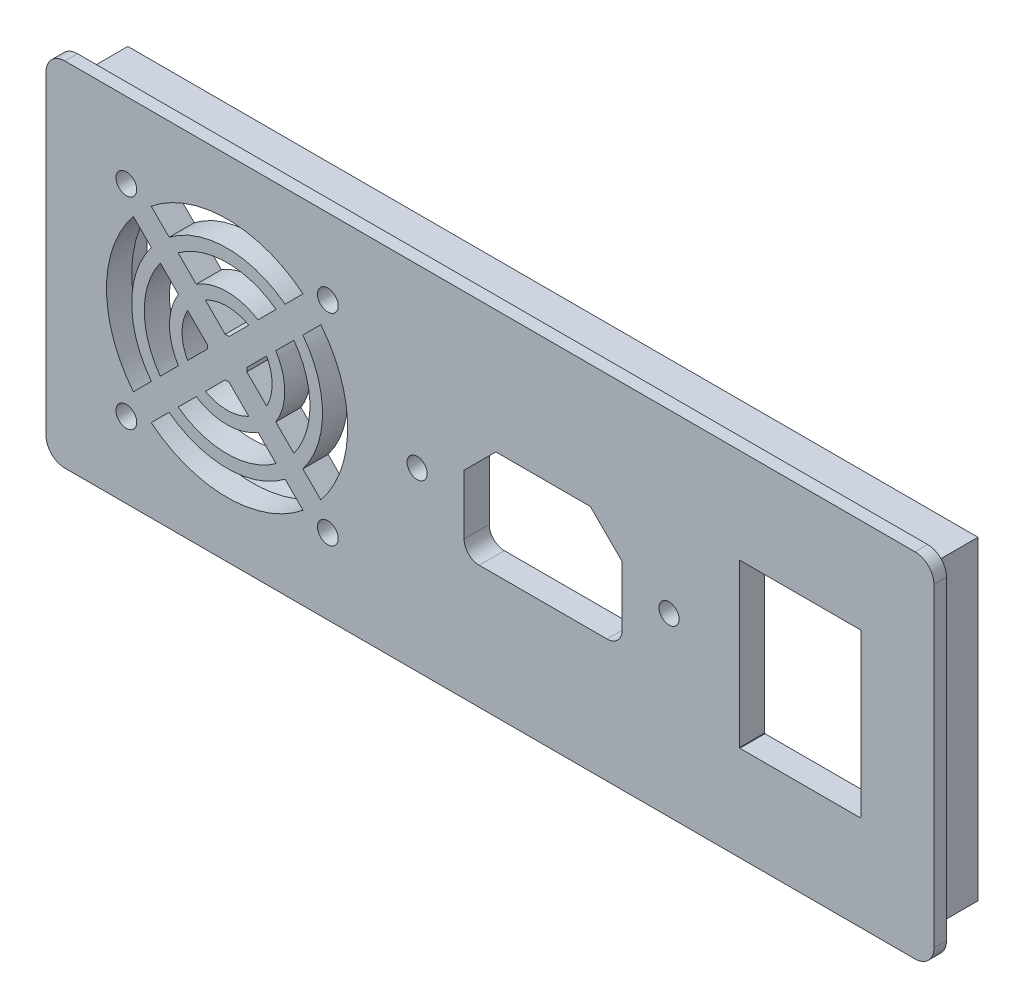
from build123d import *

# Parameters (mm, degrees)
CROQUIS1_W              = 135
CROQUIS1_H              = 50
CROQUIS1_R              = 1.65
CROQUIS1_R_2            = 1.6
SALIENTE_EXTRUIR1_DEPTH = 4
CROQUIS2_W              = 135
CROQUIS2_H              = 50
SALIENTE_EXTRUIR2_DEPTH = 2
CROQUIS3_W              = 135
CROQUIS3_H              = 50
CROQUIS3_R              = 0.85
SALIENTE_EXTRUIR3_DEPTH = 6


with BuildPart() as part:
    # Croquis1 → Saliente-Extruir1 (new body)
    with BuildSketch(Plane.XY):
        with Locations((0.24843477, -0.062108693)):
            Rectangle(CROQUIS1_W, CROQUIS1_H)
        with Locations((-57.493419725, 15.937891307)):
            Circle(CROQUIS1_R, mode=Mode.SUBTRACT)
        with Locations((-25.493419725, 15.937891307)):
            Circle(CROQUIS1_R, mode=Mode.SUBTRACT)
        with Locations((-25.493419725, -16.062108693)):
            Circle(CROQUIS1_R, mode=Mode.SUBTRACT)
        with Locations((-57.493419725, -16.062108693)):
            Circle(CROQUIS1_R, mode=Mode.SUBTRACT)
        with Locations((28.686131392, -0.062108693)):
            Circle(CROQUIS1_R_2, mode=Mode.SUBTRACT)
        with Locations((-11.313868608, -0.062108693)):
            Circle(CROQUIS1_R_2, mode=Mode.SUBTRACT)
        Polygon((59.170162083, 12.86736071), (39.870162083, 12.86736071), (39.870162083, -12.93263929), (39.920162083, -12.93263929), (39.920162083, -12.991578095), (59.120162083, -12.991578095), (59.120162083, -12.93263929), (59.170162083, -12.93263929), align=None, mode=Mode.SUBTRACT)
        with BuildLine():
            Line((16.192628508, 8.387891307), (1.179634277, 8.387891307))
            Line((1.179634277, 8.387891307), (-3.863868608, 3.344388423))
            Line((-3.863868608, 3.344388423), (-3.863868608, -6.112108693))
            ThreePointArc((-3.863868608, -6.112108693), (-3.160924883, -7.809164967), (-1.463868608, -8.512108693))
            Line((-1.463868608, -8.512108693), (18.836131392, -8.512108693))
            ThreePointArc((18.836131392, -8.512108693), (20.533187667, -7.809164967), (21.236131392, -6.112108693))
            Line((21.236131392, -6.112108693), (21.236131392, 3.344388423))
            Line((21.236131392, 3.344388423), (16.192628508, 8.387891307))
        make_face(mode=Mode.SUBTRACT)
        with BuildLine():
            Line((-38.358377873, -0.368723419), (-35.225212961, -3.501888332))
            ThreePointArc((-35.225212961, -3.501888332), (-34.343419725, -0.062108693), (-35.225212961, 3.377670947))
            Line((-35.225212961, 3.377670947), (-38.358377873, 0.244506034))
            ThreePointArc((-38.358377873, 0.244506034), (-38.343419725, -0.062108693), (-38.358377873, -0.368723419))
        make_face(mode=Mode.SUBTRACT)
        with BuildLine():
            Line((-44.628461576, -0.368723419), (-47.761626488, -3.501888332))
            ThreePointArc((-47.761626488, -3.501888332), (-48.643419725, -0.062108693), (-47.761626488, 3.377670947))
            Line((-47.761626488, 3.377670947), (-44.628461576, 0.244506034))
            ThreePointArc((-44.628461576, 0.244506034), (-44.643419725, -0.062108693), (-44.628461576, -0.368723419))
        make_face(mode=Mode.SUBTRACT)
        with BuildLine():
            Line((-29.440590182, 14.819147975), (-32.288723267, 11.971014889))
            ThreePointArc((-32.288723267, 11.971014889), (-41.493419725, 15.087891307), (-50.698116182, 11.971014889))
            Line((-50.698116182, 11.971014889), (-53.546249267, 14.819147975))
            ThreePointArc((-53.546249267, 14.819147975), (-41.493419725, 19.087891307), (-29.440590182, 14.819147975))
        make_face(mode=Mode.SUBTRACT)
        with BuildLine():
            Line((-26.612163057, 11.99072085), (-29.460296143, 9.142587764))
            ThreePointArc((-29.460296143, 9.142587764), (-26.343419725, -0.062108693), (-29.460296143, -9.26680515))
            Line((-29.460296143, -9.26680515), (-26.612163057, -12.114938235))
            ThreePointArc((-26.612163057, -12.114938235), (-22.343419725, -0.062108693), (-26.612163057, 11.99072085))
        make_face(mode=Mode.SUBTRACT)
        with BuildLine():
            Line((-56.374676392, 11.99072085), (-53.526543306, 9.142587764))
            ThreePointArc((-53.526543306, 9.142587764), (-56.643419725, -0.062108693), (-53.526543306, -9.26680515))
            Line((-53.526543306, -9.26680515), (-56.374676392, -12.114938235))
            ThreePointArc((-56.374676392, -12.114938235), (-60.643419725, -0.062108693), (-56.374676392, 11.99072085))
        make_face(mode=Mode.SUBTRACT)
        with BuildLine():
            Line((-41.800034451, -3.197150544), (-44.933199364, -6.330315456))
            ThreePointArc((-44.933199364, -6.330315456), (-41.493419725, -7.212108693), (-38.053640085, -6.330315456))
            Line((-38.053640085, -6.330315456), (-41.186804998, -3.197150544))
            ThreePointArc((-41.186804998, -3.197150544), (-41.493419725, -3.212108693), (-41.800034451, -3.197150544))
        make_face(mode=Mode.SUBTRACT)
        with BuildLine():
            Line((-30.888925971, 7.713957937), (-33.765629521, 4.837254386))
            ThreePointArc((-33.765629521, 4.837254386), (-32.343419725, -0.062108693), (-33.765629521, -4.961471771))
            Line((-33.765629521, -4.961471771), (-30.888925971, -7.838175322))
            ThreePointArc((-30.888925971, -7.838175322), (-28.343419725, -0.062108693), (-30.888925971, 7.713957937))
        make_face(mode=Mode.SUBTRACT)
        with BuildLine():
            Line((-33.717353095, 10.542385061), (-36.594056646, 7.665681511))
            ThreePointArc((-36.594056646, 7.665681511), (-41.493419725, 9.087891307), (-46.392782803, 7.665681511))
            Line((-46.392782803, 7.665681511), (-49.269486354, 10.542385061))
            ThreePointArc((-49.269486354, 10.542385061), (-41.493419725, 13.087891307), (-33.717353095, 10.542385061))
        make_face(mode=Mode.SUBTRACT)
        with BuildLine():
            Line((-52.097913478, 7.713957937), (-49.221209928, 4.837254386))
            ThreePointArc((-49.221209928, 4.837254386), (-50.643419725, -0.062108693), (-49.221209928, -4.961471771))
            Line((-49.221209928, -4.961471771), (-52.097913478, -7.838175322))
            ThreePointArc((-52.097913478, -7.838175322), (-54.643419725, -0.062108693), (-52.097913478, 7.713957937))
        make_face(mode=Mode.SUBTRACT)
        with BuildLine():
            Line((-50.698116182, -12.095232274), (-53.546249267, -14.94336536))
            ThreePointArc((-53.546249267, -14.94336536), (-41.493419725, -19.212108693), (-29.440590182, -14.94336536))
            Line((-29.440590182, -14.94336536), (-32.288723267, -12.095232274))
            ThreePointArc((-32.288723267, -12.095232274), (-41.493419725, -15.212108693), (-50.698116182, -12.095232274))
        make_face(mode=Mode.SUBTRACT)
        with BuildLine():
            Line((-36.594056646, -7.789898896), (-33.717353095, -10.666602447))
            ThreePointArc((-33.717353095, -10.666602447), (-41.493419725, -13.212108693), (-49.269486354, -10.666602447))
            Line((-49.269486354, -10.666602447), (-46.392782803, -7.789898896))
            ThreePointArc((-46.392782803, -7.789898896), (-41.493419725, -9.212108693), (-36.594056646, -7.789898896))
        make_face(mode=Mode.SUBTRACT)
        with BuildLine():
            Line((-44.933199364, 6.206098071), (-41.800034451, 3.072933159))
            ThreePointArc((-41.800034451, 3.072933159), (-41.493419725, 3.087891307), (-41.186804998, 3.072933159))
            Line((-41.186804998, 3.072933159), (-38.053640085, 6.206098071))
            ThreePointArc((-38.053640085, 6.206098071), (-41.493419725, 7.087891307), (-44.933199364, 6.206098071))
        make_face(mode=Mode.SUBTRACT)
    extrude(amount=SALIENTE_EXTRUIR1_DEPTH)

    # Croquis2 → Saliente-Extruir2 (add)
    with BuildSketch(Plane.XY.offset(4)):
        with BuildLine():
            Line((70.74843477, -25.062108693), (70.74843477, 24.937891307))
            ThreePointArc((70.74843477, 24.937891307), (69.869755114, 27.059211651), (67.74843477, 27.937891307))
            Line((67.74843477, 27.937891307), (-67.25156523, 27.937891307))
            ThreePointArc((-67.25156523, 27.937891307), (-69.372885573, 27.059211651), (-70.25156523, 24.937891307))
            Line((-70.25156523, 24.937891307), (-70.25156523, -25.062108693))
            ThreePointArc((-70.25156523, -25.062108693), (-69.372885573, -27.183429036), (-67.25156523, -28.062108693))
            Line((-67.25156523, -28.062108693), (67.74843477, -28.062108693))
            ThreePointArc((67.74843477, -28.062108693), (69.869755114, -27.183429036), (70.74843477, -25.062108693))
        make_face()
        with Locations((0.24843477, -0.062108693)):
            Rectangle(CROQUIS2_W, CROQUIS2_H, mode=Mode.SUBTRACT)
    extrude(amount=-SALIENTE_EXTRUIR2_DEPTH)

    # Croquis3 → Saliente-Extruir3 (add)
    with BuildSketch(Plane(origin=(0, 0, 0), x_dir=(-1, 0, 0), z_dir=(0, 0, -1))):
        with Locations((-0.24843477, -0.062108693)):
            Rectangle(CROQUIS3_W, CROQUIS3_H)
        with Locations((-64.99843477, 22.187891307)):
            Circle(CROQUIS3_R, mode=Mode.SUBTRACT)
        with Locations((64.50156523, 22.187891307)):
            Circle(CROQUIS3_R, mode=Mode.SUBTRACT)
        with Locations((-64.99843477, -22.312108693)):
            Circle(CROQUIS3_R, mode=Mode.SUBTRACT)
        with Locations((64.50156523, -22.312108693)):
            Circle(CROQUIS3_R, mode=Mode.SUBTRACT)
        Polygon((-64.74843477, 16.937891307), (-64.74843477, -17.062108693), (-59.74843477, -22.062108693), (59.25156523, -22.062108693), (64.25156523, -17.062108693), (64.25156523, 16.937891307), (59.25156523, 21.937891307), (-59.74843477, 21.937891307), align=None, mode=Mode.SUBTRACT)
    extrude(amount=SALIENTE_EXTRUIR3_DEPTH)


solid = part.part
